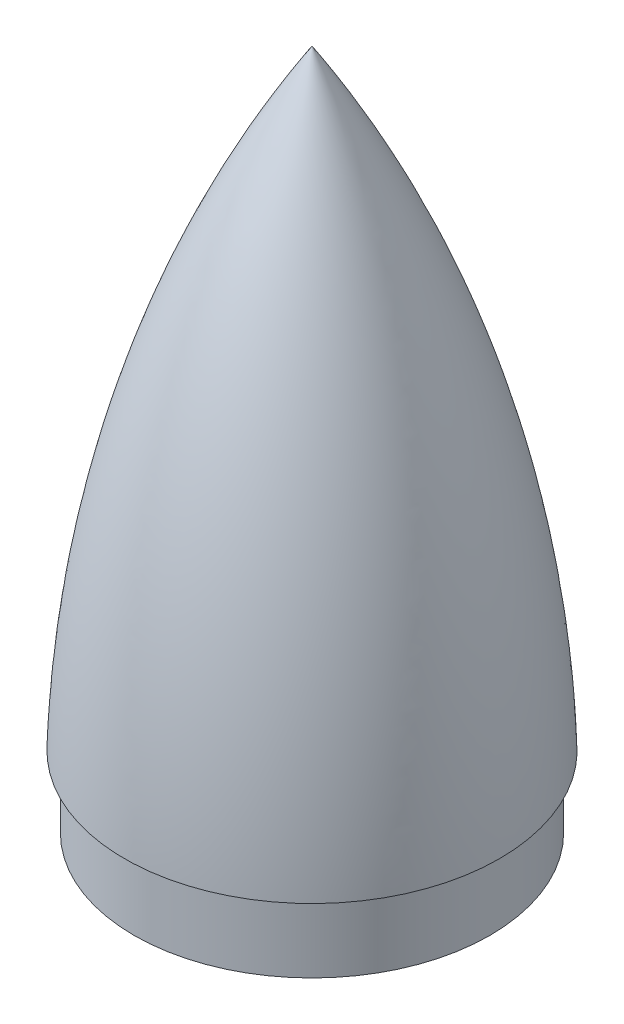
from build123d import *

# Parameters (mm, degrees)
SKETCH3_R           = 88.9
SKETCH3_R_2         = 86.995
BOSS_EXTRUDE1_DEPTH = 35.56


with BuildPart() as part:
    # Sketch2 → Revolve1 (revolve)
    with BuildSketch(Plane.XY):
        with BuildLine():
            Line((-93.6498, 0), (-88.9, 0))
            ThreePointArc((-88.9, 0), (-62.950771459, 155.347516958), (0, 299.72))
            Line((0, 299.72), (0, 304.8))
            ThreePointArc((0, 304.8), (-67.390449504, 158.718765085), (-93.6498, 0))
        make_face()
    revolve(axis=Axis((0, 304.8, 0), (0, -1, 0)))


with BuildPart() as body_2:
    # Sketch3 → Boss-Extrude1 (new body)
    with BuildSketch(Plane.XZ):
        Circle(SKETCH3_R)
        Circle(SKETCH3_R_2, mode=Mode.SUBTRACT)
    extrude(amount=BOSS_EXTRUDE1_DEPTH)


solid = Compound([part.part, body_2.part])
